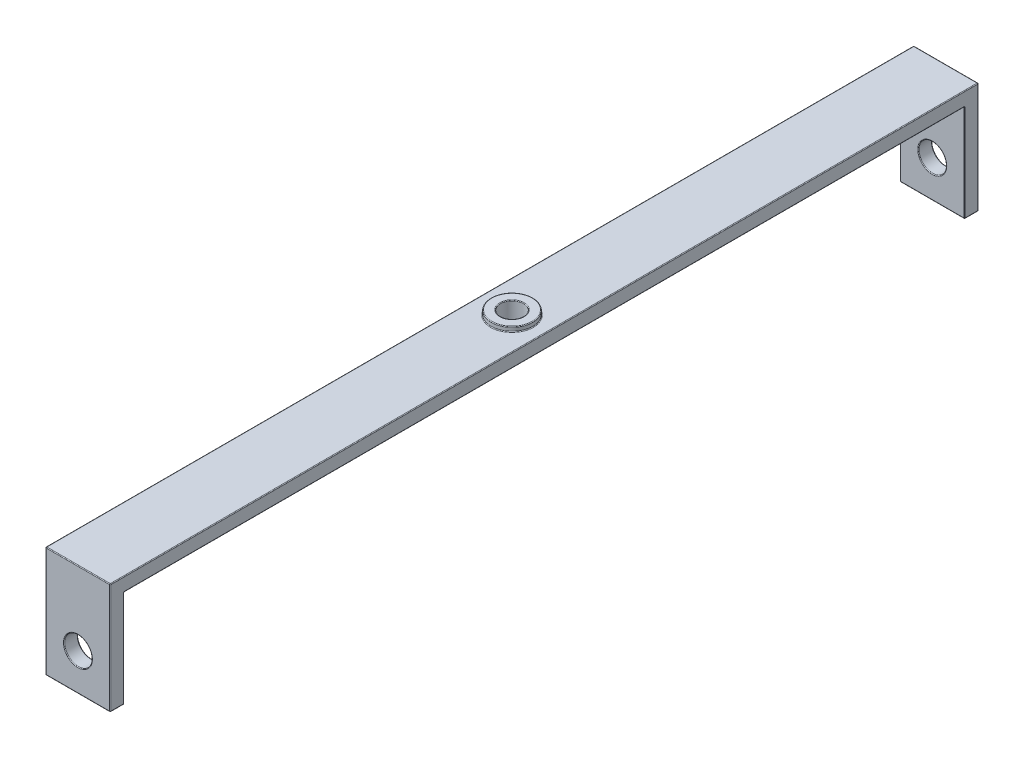
from build123d import *

# Parameters (mm, degrees)
BOSS_EXTRUDE1_DEPTH      = 3.5
BOSS_EXTRUDE1_DEPTH_BACK = 3.5
SKETCH2_R                = 1.25
CUT_EXTRUDE1_DEPTH       = 1.5
SKETCH3_R                = 2.25
SKETCH3_R_2              = 1.25
BOSS_EXTRUDE3_DEPTH      = 0.5
SKETCH5_R                = 1.5
CUT_EXTRUDE5_DEPTH       = 48
CUT_EXTRUDE5_DEPTH_BACK  = 48
FILLET1_R                = 0.075


with BuildPart() as part:
    # Sketch1 → Boss-Extrude1 (new body, two sides)
    with BuildSketch(Plane(origin=(0, 0, 0), x_dir=(0, 0, -1), z_dir=(1, 0, 0))) as boss_extrude1_sk:
        Polygon((-47, -12), (-47, 0), (47, 0), (47, -12), (45.5, -12), (45.5, -1.5), (-45.5, -1.5), (-45.5, -12), align=None)
    extrude(amount=BOSS_EXTRUDE1_DEPTH)
    extrude(boss_extrude1_sk.sketch, amount=-BOSS_EXTRUDE1_DEPTH_BACK)

    # Sketch2 → Cut-Extrude1 (cut)
    with BuildSketch(Plane(origin=(0, 0, 0), x_dir=(1, 0, 0), z_dir=(0, 1, 0))):
        Circle(SKETCH2_R)
    extrude(amount=-CUT_EXTRUDE1_DEPTH, mode=Mode.SUBTRACT)

    # Sketch3 → Boss-Extrude3 (add)
    with BuildSketch(Plane(origin=(0, 0, 0), x_dir=(1, 0, 0), z_dir=(0, 1, 0))):
        Circle(SKETCH3_R)
        Circle(SKETCH3_R_2, mode=Mode.SUBTRACT)
    extrude(amount=BOSS_EXTRUDE3_DEPTH)

    # Sketch5 → Cut-Extrude5 (cut, two sides)
    with BuildSketch(Plane.XY) as cut_extrude5_sk:
        with Locations((0, -8)):
            Circle(SKETCH5_R)
    extrude(amount=CUT_EXTRUDE5_DEPTH, mode=Mode.SUBTRACT)
    extrude(cut_extrude5_sk.sketch, amount=-CUT_EXTRUDE5_DEPTH_BACK, mode=Mode.SUBTRACT)

    # Fillet1
    fillet1_edges = [part.edges().sort_by_distance(p)[0] for p in [
        (-3.5, -1.5, 0),
        (0, -12, 47),
        (0, 0, 47),
        (0, 0, -47),
        (0, -12, -47),
        (0, -12, -45.5),
        (0, -1.5, -45.5),
        (0, -1.5, 45.5),
        (0, -12, 45.5),
        (-3.5, -6.75, -45.5),
        (-3.5, -12, -46.25),
        (3.5, -12, 46.25),
        (3.5, -6.75, 45.5),
        (3.5, -1.5, 0),
        (3.5, -6.75, -45.5),
        (3.5, -12, -46.25),
        (-3.5, -6, -47),
        (3.5, -6, -47),
        (3.5, 0, 0),
        (3.5, -6, 47),
        (-3.5, 0, 0),
        (-3.5, -6, 47),
        (-1.25, -1.5, 0),
        (-2.25, 0.5, 0),
        (-2.25, 0, 0),
        (-1.25, 0.5, 0),
        (-3.5, -12, 46.25),
        (-1.5, -8, 45.5),
        (-1.5, -8, -45.5),
        (-1.5, -8, -47),
        (-1.5, -8, 47),
        (-3.5, -6.75, 45.5),
    ]]
    fillet(fillet1_edges, radius=FILLET1_R)


solid = part.part
